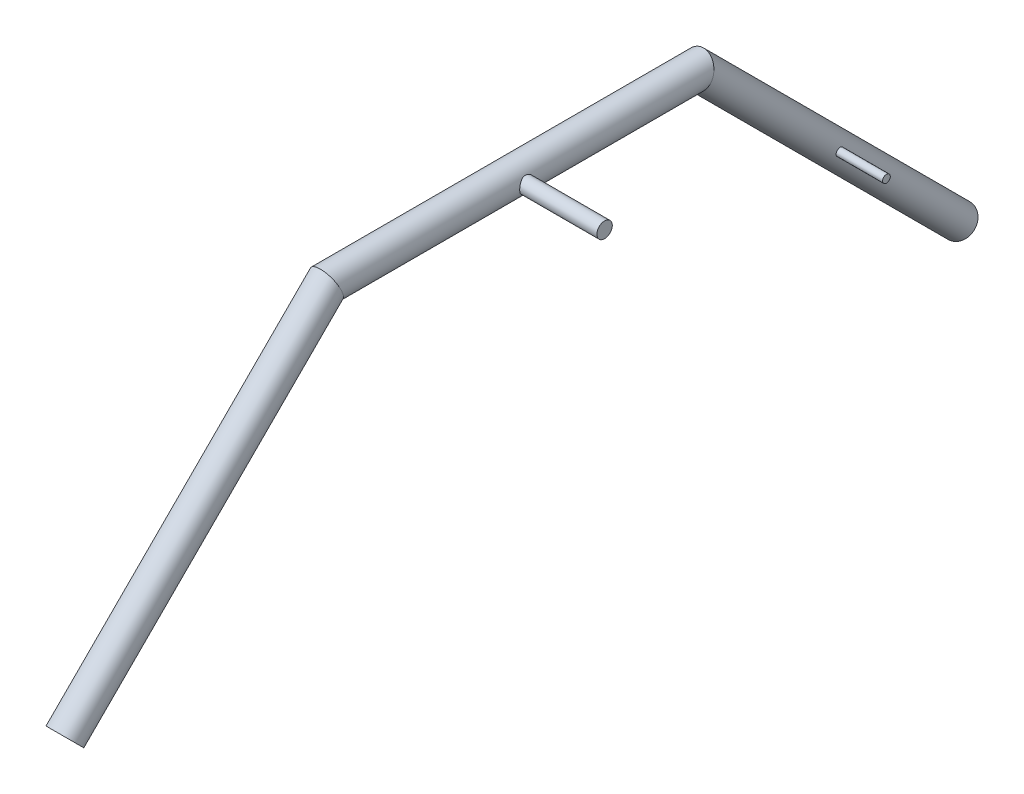
from build123d import *

# Parameters (mm, degrees)
SWEEP1_PROFILE_R     = 12.7
CUT_SWEEP1_PROFILE_R = 9.525
SKETCH19_R           = 6.35
BOSS_EXTRUDE1_DEPTH  = 76.2
SKETCH28_R           = 3.175
BOSS_EXTRUDE2_DEPTH  = 50.8


with BuildPart() as part:
    # Sweep1: sweep along a path in Sketch2
    with BuildLine(Plane(origin=(0, 0, 0), x_dir=(0, 0, -1), z_dir=(1, 0, 0))) as sweep1_path:
        Line((-248.182278836, -217.015933946), (-32.65613193, -1.489787041))
        Line((-32.65613193, -1.489787041), (272.14386807, -1.489787041))
        Line((272.14386807, -1.489787041), (487.670014975, -217.015933946))
    # Sweep1 profile (on start of the path) → Sweep1 (sweep)
    with BuildSketch(Plane(origin=(0, -217.015933946, 248.182278836), x_dir=(0, 0.7071067811865461, 0.707106781186549), z_dir=(0, 0.707106781186549, -0.7071067811865461))):
        Circle(SWEEP1_PROFILE_R)
    sweep(path=sweep1_path.line, transition=Transition.RIGHT)

    # Cut-Sweep1: sweep along a path in Sketch2_2
    with BuildLine(Plane(origin=(0, 0, 0), x_dir=(0, 0, -1), z_dir=(1, 0, 0))) as cut_sweep1_path:
        Line((-248.182278836, -217.015933946), (-32.65613193, -1.489787041))
        Line((-32.65613193, -1.489787041), (272.14386807, -1.489787041))
        Line((272.14386807, -1.489787041), (487.670014975, -217.015933946))
    # Cut-Sweep1 profile (on start of the path) → Cut-Sweep1 (sweep, cut)
    with BuildSketch(Plane(origin=(0, -217.015933946, 248.182278836), x_dir=(0, 0.7071067811865461, 0.707106781186549), z_dir=(0, 0.707106781186549, -0.7071067811865461))):
        Circle(CUT_SWEEP1_PROFILE_R)
    sweep(path=cut_sweep1_path.line, transition=Transition.RIGHT, mode=Mode.SUBTRACT)

    # Sketch19 → Boss-Extrude1 (add)
    with BuildSketch(Plane(origin=(0, 0, 0), x_dir=(0, 0, -1), z_dir=(1, 0, 0))):
        with Locations((119.74386807, -1.489787041)):
            Circle(SKETCH19_R)
    extrude(amount=BOSS_EXTRUDE1_DEPTH)

    # Sketch28 → Boss-Extrude2 (add)
    with BuildSketch(Plane(origin=(0, 0, 0), x_dir=(0, 0, -1), z_dir=(1, 0, 0))):
        with Locations((377.089758854, -106.435677825)):
            Circle(SKETCH28_R)
    extrude(amount=BOSS_EXTRUDE2_DEPTH)


solid = part.part
